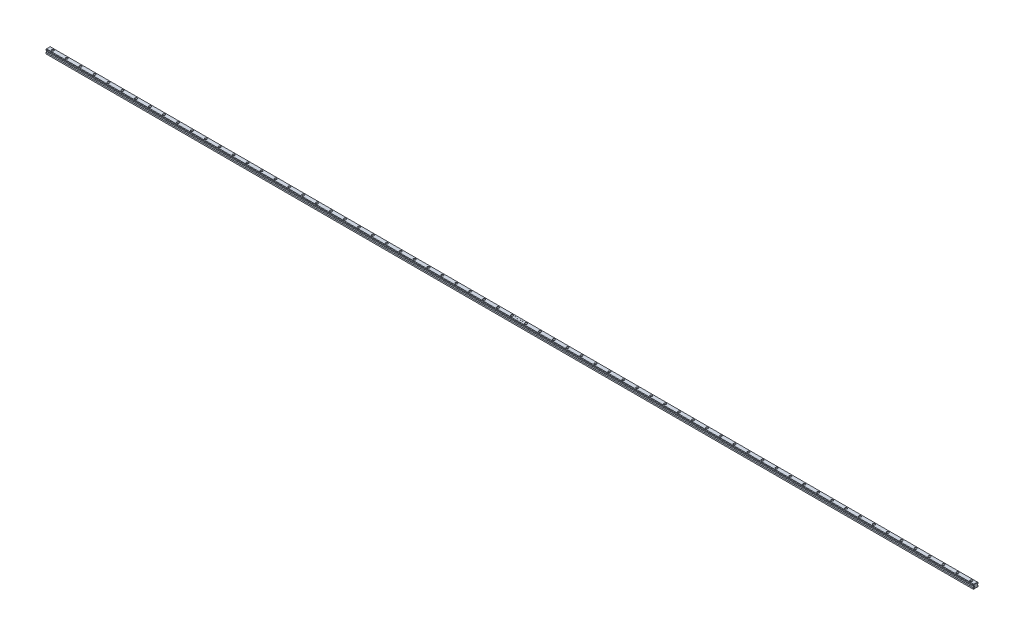
from build123d import *

# Parameters (mm, degrees)
BOSS_EXTRUDE1_DEPTH = 4000
CHAMFER1_SIZE       = 1
CHAMFER2_SIZE       = 1
SKETCH2_R           = 4.75
CUT_EXTRUDE1_DEPTH  = 8.5
SKETCH3_R           = 3
CUT_EXTRUDE2_DEPTH  = 10.5
LPATTERN1_COUNT     = 67
LPATTERN1_PITCH     = 60
CUT_EXTRUDE3_DEPTH  = 2


with BuildPart() as part:
    # Sketch1 → Boss-Extrude1 (new body)
    with BuildSketch(Plane(origin=(0, 0, 0), x_dir=(0, 0, -1), z_dir=(1, 0, 0))):
        Polygon((-10, 0), (10, 0), (10, 6), (7, 8), (7, 10), (10, 13), (10, 16), (8, 18), (-8, 18), (-10, 16), (-10, 13), (-7, 10), (-7, 8), (-10, 6), align=None)
    extrude(amount=BOSS_EXTRUDE1_DEPTH)

    # Chamfer1
    chamfer1_edges = [part.edges().sort_by_distance(p)[0] for p in [
        (0, 7, 8.5),
        (0, 9, 7),
        (0, 11.5, 8.5),
        (0, 14.5, 10),
        (0, 17, 9),
        (0, 18, 0),
        (0, 17, -9),
        (0, 14.5, -10),
        (0, 11.5, -8.5),
        (0, 9, -7),
        (0, 7, -8.5),
        (0, 3, -10),
        (0, 0, 0),
        (0, 3, 10),
    ]]
    chamfer(chamfer1_edges, length=CHAMFER1_SIZE)

    # Chamfer2
    chamfer2_edges = [part.edges().sort_by_distance(p)[0] for p in [
        (4000, 3, -10),
        (4000, 7, -8.5),
        (4000, 9, -7),
        (4000, 11.5, -8.5),
        (4000, 14.5, -10),
        (4000, 17, -9),
        (4000, 18, 0),
        (4000, 17, 9),
        (4000, 14.5, 10),
        (4000, 11.5, 8.5),
        (4000, 3, 10),
        (4000, 9, 7),
        (4000, 7, 8.5),
        (4000, 0, 0),
    ]]
    chamfer(chamfer2_edges, length=CHAMFER2_SIZE)

    # Sketch2 → Cut-Extrude1 (cut)
    with BuildSketch(Plane(origin=(0, 18, 0), x_dir=(1, 0, 0), z_dir=(0, 1, 0))):
        with Locations(Location((3980, 0, 0), (0, 0, 270))):  # turned: the seam where the file's is
            Circle(SKETCH2_R)
    cut_extrude1 = extrude(amount=-CUT_EXTRUDE1_DEPTH, mode=Mode.SUBTRACT)

    # Sketch3 → Cut-Extrude2 (cut, through all)
    with BuildSketch(Plane(origin=(0, 9.5, 0), x_dir=(1, 0, 0), z_dir=(0, 1, 0))):
        with Locations(Location((3980, 0, 0), (0, 0, 270))):  # turned: the seam where the file's is
            Circle(SKETCH3_R)
    cut_extrude2 = extrude(amount=-CUT_EXTRUDE2_DEPTH, mode=Mode.SUBTRACT)

    # LPattern1: Cut-Extrude1, Cut-Extrude2 ×67
    with Locations(*[(-i * LPATTERN1_PITCH, 0, 0) for i in range(1, LPATTERN1_COUNT)]):
        add(cut_extrude1, mode=Mode.SUBTRACT)
        add(cut_extrude2, mode=Mode.SUBTRACT)

    # Sketch4 → Cut-Extrude3 (cut)
    with BuildSketch(Plane(origin=(0, 18, 0), x_dir=(1, 0, 0), z_dir=(0, 1, 0))):
        with BuildLine():
            Line((2010.764930285, -0.382426748), (2011.060803683, -0.205042934))
            add(Edge.make_bspline(
                [(2011.060803683, -0.205042934), (2011.08832192, -0.251107319), (2011.1410458, -0.339364903), (2011.22899716, -0.458622943), (2011.320130071, -0.5599851), (2011.415119404, -0.642861708), (2011.513385352, -0.708110594), (2011.615569406, -0.754312826), (2011.721327217, -0.783128801), (2011.793301038, -0.786628888), (2011.82923317, -0.788376267)],
                knots=[0, 0, 0, 0, 1.272034388, 2.437168799, 3.508375237, 4.49857839, 5.41946034, 6.295179144, 7.148887113, 8, 8, 8, 8], degree=3))
            add(Edge.make_bspline(
                [(2011.82923317, -0.788376267), (2011.85992003, -0.787521595), (2011.920756803, -0.785827205), (2012.010319046, -0.769546402), (2012.097300849, -0.744534274), (2012.179909486, -0.708713342), (2012.257005101, -0.665374856), (2012.324611796, -0.613028679), (2012.383057909, -0.554422473), (2012.430867024, -0.489039818), (2012.467547059, -0.41872267), (2012.495739128, -0.346546719), (2012.511384201, -0.27137815), (2012.513740955, -0.220767687), (2012.514930285, -0.195227229)],
                knots=[0, 0, 0, 0, 1.095163259, 2.171163733, 3.241058638, 4.321873601, 5.38011039, 6.391990106, 7.366004449, 8.327778327, 9.272591725, 10.192022065, 11.087607919, 12, 12, 12, 12], degree=3))
            add(Edge.make_bspline(
                [(2012.514930285, -0.195227229), (2012.513455974, -0.166086379), (2012.510458916, -0.10684729), (2012.485127436, -0.019447637), (2012.445278189, 0.067044933), (2012.408515546, 0.120546199), (2012.389429484, 0.148322451)],
                knots=[0, 0, 0, 0, 0.938893495, 1.908633276, 2.914225137, 4, 4, 4, 4], degree=3))
            add(Edge.make_bspline(
                [(2012.389429484, 0.148322451), (2012.37375887, 0.168369274), (2012.340860375, 0.210455073), (2012.284302863, 0.273100308), (2012.217936748, 0.337718727), (2012.144033194, 0.406777784), (2012.059900105, 0.477065581), (2011.96817259, 0.551933859), (2011.866508731, 0.628535436), (2011.795209235, 0.679908001), (2011.758419868, 0.706415399)],
                knots=[0, 0, 0, 0, 0.722233717, 1.516239348, 2.393582979, 3.351407094, 4.387010283, 5.505090956, 6.712668013, 8, 8, 8, 8], degree=3))
            add(Edge.make_bspline(
                [(2011.758419868, 0.706415399), (2011.721595872, 0.732643987), (2011.651191196, 0.782791049), (2011.552732613, 0.857215333), (2011.46468815, 0.925259203), (2011.387449134, 0.987563215), (2011.321049537, 1.04413582), (2011.264966126, 1.094433759), (2011.220627569, 1.13981732), (2011.195971988, 1.169258661), (2011.18490224, 1.182477098)],
                knots=[0, 0, 0, 0, 1.452282411, 2.77665338, 3.964542531, 5.026858415, 5.96415736, 6.766646006, 7.446254459, 8, 8, 8, 8], degree=3))
            add(Edge.make_bspline(
                [(2011.18490224, 1.182477098), (2011.169429695, 1.203078135), (2011.139000858, 1.243592839), (2011.098834853, 1.306917696), (2011.06469569, 1.371740962), (2011.037933358, 1.438236826), (2011.015397139, 1.505471755), (2011.000239208, 1.574323001), (2010.990747811, 1.64448162), (2010.989775825, 1.69169512), (2010.989289259, 1.715329662)],
                knots=[0, 0, 0, 0, 1.068054152, 2.10047183, 3.106115577, 4.101338837, 5.06977816, 6.043150881, 7.020423561, 8, 8, 8, 8], degree=3))
            add(Edge.make_bspline(
                [(2010.989289259, 1.715329662), (2010.990594468, 1.752359437), (2010.993176989, 1.825627501), (2011.015017506, 1.932658331), (2011.049490399, 2.034844748), (2011.097785287, 2.131175082), (2011.16004264, 2.219141063), (2011.232088615, 2.29975455), (2011.317900101, 2.367523132), (2011.412052724, 2.42673519), (2011.515109096, 2.473081116), (2011.6231, 2.508042096), (2011.736197072, 2.527851353), (2011.812800206, 2.530694118), (2011.851669067, 2.532136553)],
                knots=[0, 0, 0, 0, 1.005424448, 1.989358655, 2.955360095, 3.929531133, 4.905563448, 5.876582895, 6.856512386, 7.866279853, 8.892233794, 9.918561126, 10.94386622, 12, 12, 12, 12], degree=3))
            add(Edge.make_bspline(
                [(2011.851669067, 2.532136553), (2011.892913167, 2.530714002), (2011.974934519, 2.527885001), (2012.095583735, 2.503287469), (2012.211744451, 2.462586797), (2012.305187716, 2.416398139), (2012.378320477, 2.370266724), (2012.43409321, 2.328246899), (2012.490610661, 2.279871791), (2012.548328716, 2.225012545), (2012.606269375, 2.163165794), (2012.665292827, 2.094755105), (2012.725537096, 2.020198549), (2012.764292956, 1.966974048), (2012.784161054, 1.939688637)],
                knots=[0, 0, 0, 0, 1.286793592, 2.559021753, 3.825965368, 5.121522368, 5.803751409, 6.523245864, 7.299691795, 8.125521123, 9.008227632, 9.944561021, 10.946284179, 12, 12, 12, 12], degree=3))
            Line((2012.784161054, 1.939688637), (2012.500206727, 1.724444246))
            add(Edge.make_bspline(
                [(2012.500206727, 1.724444246), (2012.483060795, 1.746532936), (2012.450041738, 1.789070589), (2012.399912251, 1.848641905), (2012.352663603, 1.903058384), (2012.306113203, 1.950323512), (2012.262719572, 1.993025646), (2012.22060253, 2.029585403), (2012.180368178, 2.060360998), (2012.129651268, 2.093204558), (2012.065933549, 2.125761061), (2011.985949013, 2.15331014), (2011.902362738, 2.169865201), (2011.845433107, 2.172054089), (2011.816612977, 2.173162194)],
                knots=[0, 0, 0, 0, 1.181633172, 2.275549214, 3.290209073, 4.226197932, 5.078386478, 5.862611352, 6.581680152, 7.217281963, 8.414376989, 9.595101626, 10.782541182, 12, 12, 12, 12], degree=3))
            add(Edge.make_bspline(
                [(2011.816612977, 2.173162194), (2011.780456455, 2.171950494), (2011.710732008, 2.169613845), (2011.611741772, 2.14409386), (2011.522647846, 2.103911999), (2011.446095281, 2.047597021), (2011.382358304, 1.980876029), (2011.336252846, 1.904097174), (2011.308502681, 1.819314771), (2011.305116401, 1.760173115), (2011.303391824, 1.73005322)],
                knots=[0, 0, 0, 0, 1.14458467, 2.207223713, 3.21896685, 4.227309161, 5.202851033, 6.127160689, 7.046193047, 8, 8, 8, 8], degree=3))
            add(Edge.make_bspline(
                [(2011.303391824, 1.73005322), (2011.30378495, 1.711301741), (2011.304571846, 1.673768122), (2011.315546644, 1.6183167), (2011.329645973, 1.563005361), (2011.351988605, 1.508082778), (2011.382833908, 1.452588419), (2011.423339084, 1.395566681), (2011.474352396, 1.336514972), (2011.513429409, 1.298107599), (2011.534060894, 1.277829662)],
                knots=[0, 0, 0, 0, 0.858281714, 1.717966888, 2.583508476, 3.4729293, 4.427298488, 5.488583878, 6.674047936, 8, 8, 8, 8], degree=3))
            add(Edge.make_bspline(
                [(2011.534060894, 1.277829662), (2011.541722267, 1.270992636), (2011.559923934, 1.254749428), (2011.593199859, 1.228157147), (2011.637142658, 1.195354375), (2011.690604859, 1.154767059), (2011.754572221, 1.107685597), (2011.829051777, 1.054711984), (2011.913213309, 0.994126525), (2011.972935225, 0.951768985), (2012.004513618, 0.92937213)],
                knots=[0, 0, 0, 0, 0.420754252, 0.999615792, 1.744751191, 2.668019286, 3.750313428, 4.999500688, 6.413464383, 8, 8, 8, 8], degree=3))
            add(Edge.make_bspline(
                [(2012.004513618, 0.92937213), (2012.042499532, 0.901730771), (2012.116053988, 0.848207109), (2012.220711568, 0.767791429), (2012.315605376, 0.68914366), (2012.40106858, 0.612766053), (2012.477945488, 0.53923796), (2012.545383209, 0.46767478), (2012.604068889, 0.398589207), (2012.667248108, 0.310016631), (2012.731805927, 0.201235547), (2012.787247435, 0.067957309), (2012.822205782, -0.065839012), (2012.826777297, -0.155765848), (2012.829032849, -0.200135081)],
                knots=[0, 0, 0, 0, 1.163667725, 2.253281268, 3.268753668, 4.215851969, 5.092017293, 5.902905408, 6.650798638, 7.335211899, 8.59617414, 9.77448103, 10.901945474, 12, 12, 12, 12], degree=3))
            add(Edge.make_bspline(
                [(2012.829032849, -0.200135081), (2012.828375711, -0.231513446), (2012.827074196, -0.29366083), (2012.812113282, -0.384915907), (2012.790193617, -0.473546777), (2012.757156383, -0.558457889), (2012.716833225, -0.641202652), (2012.665666977, -0.719610552), (2012.606359292, -0.795416951), (2012.538325527, -0.866600442), (2012.463879625, -0.931946638), (2012.38519593, -0.9900757), (2012.302145657, -1.038544023), (2012.215179341, -1.078094865), (2012.124277004, -1.109028382), (2012.02946922, -1.131441252), (2011.930599709, -1.145196963), (2011.863399227, -1.146624724), (2011.82923317, -1.147350626)],
                knots=[0, 0, 0, 0, 0.983748083, 1.948392443, 2.894712957, 3.844097841, 4.80183111, 5.778335162, 6.776009319, 7.81870978, 8.863265674, 9.881300176, 10.883814829, 11.87499822, 12.874611388, 13.892143829, 14.928324115, 16, 16, 16, 16], degree=3))
            add(Edge.make_bspline(
                [(2011.82923317, -1.147350626), (2011.802797827, -1.146839445), (2011.750260067, -1.145823519), (2011.672550585, -1.136842239), (2011.596410996, -1.124135135), (2011.522796714, -1.103961065), (2011.450759302, -1.079484088), (2011.380612067, -1.049345756), (2011.312321014, -1.013228554), (2011.245503431, -0.97193353), (2011.180329256, -0.923875785), (2011.117409788, -0.867902289), (2011.054680603, -0.805556784), (2010.993993206, -0.73514622), (2010.934120062, -0.657808137), (2010.876241653, -0.572818954), (2010.819159935, -0.4806416), (2010.783344467, -0.415776514), (2010.764930285, -0.382426748)],
                knots=[0, 0, 0, 0, 0.915332311, 1.819136955, 2.706846663, 3.586547465, 4.459518054, 5.340707479, 6.227863349, 7.133153174, 8.059268498, 9.028702269, 10.047606654, 11.120612155, 12.245963614, 13.433783089, 14.680604001, 16, 16, 16, 16], degree=3))
        make_face()
        Polygon((2015.62005849, 2.442392963), (2015.934161054, 2.442392963), (2015.934161054, 1.006495528), (2017.729032849, 1.006495528), (2017.729032849, 2.442392963), (2018.043135413, 2.442392963), (2018.043135413, -1.057607037), (2017.729032849, -1.057607037), (2017.729032849, 0.647521169), (2015.934161054, 0.647521169), (2015.934161054, -1.057607037), (2015.62005849, -1.057607037), align=None)
        Polygon((2021.013648234, -1.057607037), (2021.013648234, 2.442392963), (2021.079553683, 2.442392963), (2023.391853362, -0.312314569), (2023.391853362, 2.442392963), (2023.705955926, 2.442392963), (2023.705955926, -1.057607037), (2023.634441503, -1.057607037), (2021.327750798, 1.690790399), (2021.327750798, -1.057607037), align=None)
        with BuildLine():
            Line((2030.230314901, 1.365469887), (2029.916212336, 1.365469887))
            add(Edge.make_bspline(
                [(2029.916212336, 1.365469887), (2029.918259489, 1.407140774), (2029.922280043, 1.488981289), (2029.941108333, 1.608305195), (2029.96804921, 1.722359994), (2030.006140664, 1.830229908), (2030.053446942, 1.932868715), (2030.110176969, 2.029868731), (2030.17737082, 2.12085992), (2030.253577554, 2.204998763), (2030.336346193, 2.282186334), (2030.425652132, 2.348841577), (2030.519497159, 2.405159248), (2030.617596558, 2.45224049), (2030.721057122, 2.487580336), (2030.82893998, 2.513801975), (2030.941719116, 2.529578321), (2031.018559138, 2.531274107), (2031.057638618, 2.532136553)],
                knots=[0, 0, 0, 0, 1.10065271, 2.161652631, 3.183658789, 4.190468796, 5.17591951, 6.163126047, 7.15150782, 8.156236427, 9.156009102, 10.134482811, 11.092018607, 12.041330605, 13.001268258, 13.972401359, 14.968799086, 16, 16, 16, 16], degree=3))
            add(Edge.make_bspline(
                [(2031.057638618, 2.532136553), (2031.096016693, 2.531238097), (2031.171428237, 2.529472662), (2031.281490252, 2.514311633), (2031.386267546, 2.490566041), (2031.485555313, 2.457250625), (2031.578561377, 2.412466197), (2031.665984422, 2.358668659), (2031.748865233, 2.296448827), (2031.823472016, 2.223195014), (2031.891980095, 2.144992629), (2031.951082351, 2.061504726), (2032.001695514, 1.97527544), (2032.043883194, 1.885647238), (2032.074939333, 1.79177621), (2032.098517541, 1.695029007), (2032.111844955, 1.594404196), (2032.113890378, 1.526297641), (2032.114930285, 1.49167181)],
                knots=[0, 0, 0, 0, 1.111607364, 2.184268762, 3.212621178, 4.221274766, 5.211760367, 6.196651075, 7.1921475, 8.207485113, 9.220403448, 10.201281604, 11.166441695, 12.114753415, 13.065576456, 14.026450734, 14.996634279, 16, 16, 16, 16], degree=3))
            add(Edge.make_bspline(
                [(2032.114930285, 1.49167181), (2032.113237022, 1.442923975), (2032.109880211, 1.346283761), (2032.081165834, 1.204268899), (2032.036319323, 1.06667548), (2031.982321966, 0.955938177), (2031.927849522, 0.866704684), (2031.878762015, 0.793235979), (2031.821297204, 0.71413051), (2031.754618706, 0.629653173), (2031.680105834, 0.539142268), (2031.59708367, 0.442652473), (2031.504960188, 0.341180703), (2031.440301687, 0.271875101), (2031.406797272, 0.235962675)],
                knots=[0, 0, 0, 0, 1.184426356, 2.348067706, 3.509069118, 4.696110526, 5.333549288, 6.050745305, 6.844228056, 7.710549037, 8.667450064, 9.695053472, 10.805634456, 12, 12, 12, 12], degree=3))
            Line((2031.406797272, 0.235962675), (2030.531096151, -0.698632678))
            Line((2030.531096151, -0.698632678), (2032.15980208, -0.698632678))
            Line((2032.15980208, -0.698632678), (2032.15980208, -1.057607037))
            Line((2032.15980208, -1.057607037), (2029.781596952, -1.057607037))
            Line((2029.781596952, -1.057607037), (2031.138968747, 0.390910592))
            add(Edge.make_bspline(
                [(2031.138968747, 0.390910592), (2031.172016633, 0.425408898), (2031.235494861, 0.491673085), (2031.325277437, 0.588416045), (2031.405916426, 0.678165586), (2031.477933818, 0.760752134), (2031.539767324, 0.837383702), (2031.594639556, 0.905578406), (2031.638605147, 0.968332856), (2031.686320542, 1.04107347), (2031.732534524, 1.129885787), (2031.77224688, 1.238419476), (2031.796461728, 1.350146729), (2031.799366564, 1.425648766), (2031.800827721, 1.463626938)],
                knots=[0, 0, 0, 0, 1.329631726, 2.553950428, 3.673215718, 4.687767853, 5.603093632, 6.413772471, 7.123043292, 7.734684054, 8.834405432, 9.900288307, 10.943827018, 12, 12, 12, 12], degree=3))
            add(Edge.make_bspline(
                [(2031.800827721, 1.463626938), (2031.800191979, 1.487508336), (2031.798939053, 1.534573987), (2031.787881355, 1.603579746), (2031.771170849, 1.670144559), (2031.747225591, 1.734473179), (2031.715618851, 1.795918831), (2031.677145471, 1.854556311), (2031.632755408, 1.911245276), (2031.581404138, 1.964398574), (2031.524992619, 2.01307978), (2031.465398369, 2.056203865), (2031.402348265, 2.092242976), (2031.336108143, 2.121786473), (2031.266862673, 2.144961854), (2031.194477928, 2.161020434), (2031.119153912, 2.171102918), (2031.067720416, 2.172467089), (2031.041512817, 2.173162194)],
                knots=[0, 0, 0, 0, 0.991446411, 1.95395049, 2.89581595, 3.838931463, 4.798493298, 5.75982156, 6.748411868, 7.785213223, 8.824556874, 9.840280684, 10.836137867, 11.835679398, 12.848801643, 13.863922112, 14.911575587, 16, 16, 16, 16], degree=3))
            add(Edge.make_bspline(
                [(2031.041512817, 2.173162194), (2031.014141984, 2.172447162), (2030.960390188, 2.171042957), (2030.881471155, 2.161220293), (2030.806185378, 2.144274452), (2030.734343475, 2.121097778), (2030.665823889, 2.091639229), (2030.600959845, 2.054947484), (2030.539896956, 2.011163991), (2030.482520432, 1.961523435), (2030.429656453, 1.906255834), (2030.383209577, 1.844645871), (2030.342625563, 1.777818455), (2030.30721633, 1.705953905), (2030.27846064, 1.628400125), (2030.256487489, 1.54543242), (2030.239100643, 1.457411038), (2030.233292122, 1.396625954), (2030.230314901, 1.365469887)],
                knots=[0, 0, 0, 0, 1.031018746, 2.02475058, 2.990194455, 3.934040569, 4.864654155, 5.795059489, 6.735614925, 7.690564532, 8.649604399, 9.611025574, 10.590972636, 11.591080095, 12.624614302, 13.701020113, 14.821632451, 16, 16, 16, 16], degree=3))
        make_face()
        with BuildLine():
            add(Edge.make_bspline(
                [(2034.546981567, 0.69099072), (2034.547309585, 0.747088108), (2034.547946765, 0.856058092), (2034.555035186, 1.014842734), (2034.566810529, 1.163803023), (2034.582947901, 1.302946089), (2034.602585882, 1.432307853), (2034.628801368, 1.551542611), (2034.658614171, 1.661202217), (2034.693166617, 1.761644266), (2034.732154406, 1.854221969), (2034.774588666, 1.94064717), (2034.822153461, 2.020789102), (2034.872130374, 2.095926893), (2034.926542445, 2.164830588), (2034.983841236, 2.22847325), (2035.046263112, 2.285384001), (2035.11168612, 2.337230303), (2035.180702585, 2.382679775), (2035.251345251, 2.422712513), (2035.324100357, 2.456912381), (2035.39916654, 2.483802816), (2035.475869098, 2.506013663), (2035.554476164, 2.521202611), (2035.635117528, 2.530759519), (2035.689548963, 2.531673187), (2035.717153843, 2.532136553)],
                knots=[0, 0, 0, 0, 1.646270934, 3.197905019, 4.663502075, 6.030701355, 7.308322542, 8.50163776, 9.611534131, 10.641858119, 11.616356847, 12.558055219, 13.465016945, 14.349605745, 15.204443733, 16.039544428, 16.859896111, 17.680448484, 18.487036065, 19.28249412, 20.06191084, 20.843045899, 21.620316918, 22.403196591, 23.190181807, 24, 24, 24, 24], degree=3))
            add(Edge.make_bspline(
                [(2035.717153843, 2.532136553), (2035.744989321, 2.531648738), (2035.80034533, 2.530678627), (2035.882185705, 2.521354685), (2035.962135387, 2.505883562), (2036.039853526, 2.483962587), (2036.115978512, 2.45676691), (2036.18991492, 2.422679793), (2036.262122002, 2.383000926), (2036.331452289, 2.336377049), (2036.398666904, 2.284394772), (2036.462114867, 2.225632104), (2036.521801953, 2.160682384), (2036.578477259, 2.09024052), (2036.630532856, 2.012955436), (2036.680106288, 1.930171326), (2036.724478324, 1.840440461), (2036.767212999, 1.745259993), (2036.804099986, 1.641996334), (2036.837366231, 1.531231574), (2036.8642452, 1.411657387), (2036.886634472, 1.283901142), (2036.903979368, 1.147493658), (2036.91661201, 1.002727343), (2036.923285095, 0.849506952), (2036.924541796, 0.744749103), (2036.925186695, 0.69099072)],
                knots=[0, 0, 0, 0, 0.810914788, 1.612654377, 2.396697861, 3.181598691, 3.963628158, 4.749916497, 5.551656086, 6.361998678, 7.18212741, 8.025565596, 8.878627764, 9.750805457, 10.657531673, 11.591944965, 12.560506719, 13.57287815, 14.630710178, 15.753379473, 16.941251878, 18.199788006, 19.531962791, 20.947069417, 22.433333509, 24, 24, 24, 24], degree=3))
            add(Edge.make_bspline(
                [(2036.925186695, 0.69099072), (2036.924535111, 0.637466812), (2036.923265525, 0.53317766), (2036.916686818, 0.380646685), (2036.903728187, 0.236648641), (2036.887518199, 0.100838179), (2036.865067236, -0.02621944), (2036.837462069, -0.144963888), (2036.806811747, -0.25590796), (2036.768976953, -0.358142772), (2036.727566242, -0.453094494), (2036.682511046, -0.541761643), (2036.63424122, -0.624927935), (2036.581652475, -0.701927682), (2036.525599062, -0.773306339), (2036.464881273, -0.837803962), (2036.401210688, -0.896974634), (2036.333798272, -0.949626262), (2036.263386721, -0.995711066), (2036.191427644, -1.036924917), (2036.11664426, -1.070157612), (2036.040731308, -1.098692653), (2035.962602942, -1.120493104), (2035.882356551, -1.13556696), (2035.800400315, -1.146138808), (2035.74499875, -1.146945288), (2035.717153843, -1.147350626)],
                knots=[0, 0, 0, 0, 1.561518951, 3.042555995, 4.452378317, 5.7783523, 7.031515105, 8.214008947, 9.334062868, 10.386615937, 11.391082383, 12.354592575, 13.286541444, 14.194233754, 15.072674879, 15.931287219, 16.775624067, 17.606195743, 18.42308326, 19.229000347, 20.022332153, 20.807536673, 21.593273796, 22.3848459, 23.188221202, 24, 24, 24, 24], degree=3))
            add(Edge.make_bspline(
                [(2035.717153843, -1.147350626), (2035.689549729, -1.146884271), (2035.635119804, -1.145964709), (2035.554467379, -1.136450977), (2035.476184935, -1.121155474), (2035.399886181, -1.09973887), (2035.325179666, -1.073524034), (2035.253083379, -1.03937035), (2035.182795696, -1.000036281), (2035.11450414, -0.95524086), (2035.049491979, -0.903919177), (2034.987393373, -0.847154888), (2034.929768354, -0.783531477), (2034.876134259, -0.714053554), (2034.82516017, -0.639360311), (2034.778270797, -0.558431938), (2034.734899943, -0.471589328), (2034.695256452, -0.378271417), (2034.660107789, -0.277116489), (2034.629060081, -0.166967311), (2034.604545923, -0.046851675), (2034.583562968, 0.082265693), (2034.566638585, 0.220939623), (2034.55508426, 0.369245401), (2034.547942945, 0.52709061), (2034.547307874, 0.635360384), (2034.546981567, 0.69099072)],
                knots=[0, 0, 0, 0, 0.810891512, 1.598919785, 2.382837074, 3.152667961, 3.926044502, 4.706494248, 5.493654104, 6.291793342, 7.103789334, 7.925228297, 8.761435821, 9.622817696, 10.50288917, 11.416980706, 12.369136599, 13.353924996, 14.394355917, 15.514179734, 16.714354668, 17.994756427, 19.357759367, 20.818452758, 22.365282078, 24, 24, 24, 24], degree=3))
        make_face()
        with BuildLine():
            add(Edge.make_bspline(
                [(2034.861084131, 0.692392963), (2034.861203578, 0.645644265), (2034.861435402, 0.55491422), (2034.867491602, 0.423070959), (2034.875741834, 0.30010063), (2034.886383131, 0.185847094), (2034.90218608, 0.080697081), (2034.919892868, -0.016072602), (2034.941440957, -0.103949839), (2034.966935975, -0.18353765), (2034.995975072, -0.256186718), (2035.027680936, -0.323787933), (2035.061741659, -0.38713987), (2035.099860809, -0.445673478), (2035.141375872, -0.499579642), (2035.185349132, -0.549812475), (2035.233421716, -0.594609456), (2035.299925458, -0.648336311), (2035.387721933, -0.703855445), (2035.498342388, -0.752201535), (2035.612010839, -0.782583991), (2035.689162089, -0.786447747), (2035.72767067, -0.788376267)],
                knots=[0, 0, 0, 0, 1.459021318, 2.831673884, 4.118529203, 5.306027144, 6.411944654, 7.436330062, 8.375795394, 9.233974572, 10.042671642, 10.816086306, 11.563610507, 12.285937304, 12.993564865, 13.685989202, 14.367179055, 15.041617293, 16.353048772, 17.594441528, 18.799311195, 20, 20, 20, 20], degree=3))
            add(Edge.make_bspline(
                [(2035.72767067, -0.788376267), (2035.766428341, -0.786778486), (2035.843863665, -0.783586224), (2035.95699746, -0.752787486), (2036.06682773, -0.706317947), (2036.15289967, -0.651370441), (2036.218382214, -0.599042112), (2036.265299204, -0.554427464), (2036.308361252, -0.504471596), (2036.349203327, -0.4505723), (2036.386662403, -0.391699816), (2036.42072554, -0.328137241), (2036.451808888, -0.259708063), (2036.469517934, -0.211938324), (2036.478572112, -0.187514889)],
                knots=[0, 0, 0, 0, 1.353760809, 2.704726607, 4.075137775, 5.516104923, 6.260822281, 7.007110065, 7.778089737, 8.566572457, 9.372053459, 10.217411131, 11.088608312, 12, 12, 12, 12], degree=3))
            add(Edge.make_bspline(
                [(2036.478572112, -0.187514889), (2036.48912388, -0.15628515), (2036.510548494, -0.092875385), (2036.538160268, 0.005488267), (2036.559905667, 0.108691031), (2036.579469033, 0.216116147), (2036.592822089, 0.328555848), (2036.603569902, 0.445662232), (2036.609900589, 0.567523595), (2036.61068534, 0.650318586), (2036.611084131, 0.692392963)],
                knots=[0, 0, 0, 0, 0.884706709, 1.796334032, 2.740027952, 3.714592787, 4.726048262, 5.777819803, 6.87074269, 8, 8, 8, 8], degree=3))
            add(Edge.make_bspline(
                [(2036.611084131, 0.692392963), (2036.610533942, 0.734460536), (2036.609457654, 0.816753701), (2036.605343667, 0.937271881), (2036.594720092, 1.051739642), (2036.582920973, 1.160650115), (2036.565523752, 1.263400418), (2036.546765945, 1.360850723), (2036.521564733, 1.451793748), (2036.494644958, 1.53765333), (2036.463834562, 1.617453984), (2036.429918828, 1.69156777), (2036.393697069, 1.760352495), (2036.354354829, 1.823619437), (2036.312359146, 1.88165198), (2036.266601597, 1.933286574), (2036.218897224, 1.980123542), (2036.152080038, 2.033586111), (2036.064605748, 2.088097807), (2035.955760101, 2.138263567), (2035.842489457, 2.167071859), (2035.765916003, 2.171133546), (2035.72767067, 2.173162194)],
                knots=[0, 0, 0, 0, 1.31362396, 2.569729283, 3.763502607, 4.902122613, 5.988968491, 7.01645872, 7.998833611, 8.933434873, 9.825090667, 10.667526885, 11.477055099, 12.250526234, 12.991942729, 13.710640831, 14.402115721, 15.076753259, 16.378508321, 17.609869233, 18.806226677, 20, 20, 20, 20], degree=3))
            add(Edge.make_bspline(
                [(2035.72767067, 2.173162194), (2035.688960078, 2.171130748), (2035.611468372, 2.167064154), (2035.497020417, 2.1383709), (2035.387316066, 2.088357934), (2035.300073091, 2.033405562), (2035.233209304, 1.98106725), (2035.186126611, 1.935680796), (2035.141980439, 1.886034542), (2035.101312739, 1.831632627), (2035.063223456, 1.773167259), (2035.028242443, 1.710178495), (2034.996725113, 1.642347131), (2034.967640577, 1.569730695), (2034.942067789, 1.490149751), (2034.920973826, 1.402380757), (2034.901486773, 1.305918865), (2034.887691504, 1.200199357), (2034.875427748, 1.085917204), (2034.8675464, 0.962639886), (2034.861415143, 0.830575505), (2034.861196678, 0.739376347), (2034.861084131, 0.692392963)],
                knots=[0, 0, 0, 0, 1.207732386, 2.417664972, 3.655092373, 4.956220595, 5.625982001, 6.301752483, 6.994047911, 7.697131622, 8.419323945, 9.170223765, 9.943494443, 10.752040957, 11.610060368, 12.549350801, 13.567764191, 14.679664412, 15.874934091, 17.154273443, 18.533957287, 20, 20, 20, 20], degree=3))
        make_face(mode=Mode.SUBTRACT)
        with BuildLine():
            Line((2043.045699516, 2.442392963), (2043.728592144, 2.442392963))
            add(Edge.make_bspline(
                [(2043.728592144, 2.442392963), (2043.762020622, 2.442217213), (2043.826813333, 2.441876565), (2043.921032774, 2.436593434), (2044.009281585, 2.429389764), (2044.091585357, 2.417959671), (2044.16790606, 2.404167894), (2044.238473697, 2.387466078), (2044.303063869, 2.367439465), (2044.380176606, 2.335593183), (2044.468097267, 2.288270015), (2044.563295659, 2.21834145), (2044.644699899, 2.132808987), (2044.714886216, 2.036326331), (2044.770687336, 1.930190559), (2044.811056633, 1.816931371), (2044.836614508, 1.698009629), (2044.839242942, 1.616366451), (2044.840571311, 1.575105303)],
                knots=[0, 0, 0, 0, 1.001505555, 1.941167018, 2.826882275, 3.653841531, 4.429895133, 5.150066043, 5.825578002, 6.45369114, 7.647487171, 8.808567382, 9.977351308, 11.170798116, 12.373658725, 13.556498008, 14.765093433, 16, 16, 16, 16], degree=3))
            add(Edge.make_bspline(
                [(2044.840571311, 1.575105303), (2044.839478092, 1.536452748), (2044.837329815, 1.460496831), (2044.816787056, 1.349402721), (2044.784626387, 1.243651502), (2044.739921138, 1.143629117), (2044.681819142, 1.051595504), (2044.612960823, 0.966808238), (2044.529884021, 0.892857181), (2044.467640781, 0.851514278), (2044.436024035, 0.830513957)],
                knots=[0, 0, 0, 0, 1.044552857, 2.05264487, 3.044412934, 4.028983338, 5.005914585, 5.980388656, 6.974128949, 8, 8, 8, 8], degree=3))
            add(Edge.make_bspline(
                [(2044.436024035, 0.830513957), (2044.475784463, 0.815248958), (2044.55185601, 0.786043234), (2044.656542023, 0.73440777), (2044.746736868, 0.678245659), (2044.823134014, 0.616913809), (2044.888471668, 0.550804998), (2044.94552461, 0.478949884), (2044.994205984, 0.400411126), (2045.035918908, 0.316007591), (2045.068467664, 0.226601123), (2045.092843568, 0.133030346), (2045.106811017, 0.035630791), (2045.108798659, -0.030654588), (2045.10980208, -0.064117453)],
                knots=[0, 0, 0, 0, 1.27268992, 2.434971085, 3.483601985, 4.442670787, 5.356604649, 6.2567628, 7.179492994, 8.113709626, 9.066344395, 10.018646069, 10.999752585, 12, 12, 12, 12], degree=3))
            add(Edge.make_bspline(
                [(2045.10980208, -0.064117453), (2045.108825234, -0.098284325), (2045.106903262, -0.165508603), (2045.09272329, -0.264263738), (2045.068714183, -0.358638685), (2045.035643037, -0.449243867), (2044.992480722, -0.535904002), (2044.939952758, -0.618717266), (2044.877321194, -0.696851596), (2044.807258325, -0.771175219), (2044.72799618, -0.838003007), (2044.642480425, -0.897518713), (2044.549634105, -0.946464776), (2044.450982111, -0.987580797), (2044.345417795, -1.018987996), (2044.233415188, -1.040960569), (2044.115070886, -1.055765606), (2044.033861135, -1.056982811), (2043.992213939, -1.057607037)],
                knots=[0, 0, 0, 0, 0.978564426, 1.925352924, 2.850884081, 3.763762016, 4.682927383, 5.618979971, 6.567305752, 7.547517671, 8.540179244, 9.531824382, 10.526200242, 11.540722885, 12.589160233, 13.674978461, 14.80764778, 16, 16, 16, 16], degree=3))
            Line((2043.992213939, -1.057607037), (2043.045699516, -1.057607037))
            Line((2043.045699516, -1.057607037), (2043.045699516, 2.442392963))
        make_face()
        with BuildLine():
            Line((2043.35980208, 2.083418605), (2043.35980208, 0.961623733))
            Line((2043.35980208, 0.961623733), (2043.57083974, 0.961623733))
            add(Edge.make_bspline(
                [(2043.57083974, 0.961623733), (2043.601688536, 0.962023656), (2043.661294695, 0.962796388), (2043.747614591, 0.965009906), (2043.82773961, 0.971207949), (2043.901531443, 0.977404211), (2043.968873887, 0.987478799), (2044.029617748, 0.999470922), (2044.084716345, 1.012153827), (2044.148255891, 1.033723314), (2044.220328839, 1.065600989), (2044.297161943, 1.115072825), (2044.364896413, 1.173997178), (2044.422093601, 1.24198814), (2044.468905071, 1.316854326), (2044.501418786, 1.397401206), (2044.52346607, 1.481621338), (2044.525457602, 1.539439591), (2044.526468747, 1.568795207)],
                knots=[0, 0, 0, 0, 1.156816544, 2.235205308, 3.236616184, 4.169592532, 5.011045266, 5.787822928, 6.49130361, 7.128639758, 8.301311294, 9.436451833, 10.541879658, 11.654887649, 12.756523258, 13.837046038, 14.901820046, 16, 16, 16, 16], degree=3))
            add(Edge.make_bspline(
                [(2044.526468747, 1.568795207), (2044.525942566, 1.588220979), (2044.524910407, 1.626326751), (2044.516457104, 1.681876105), (2044.50208953, 1.734119857), (2044.483635236, 1.783773968), (2044.457846548, 1.829285818), (2044.427483084, 1.872229014), (2044.390797394, 1.911141132), (2044.349040081, 1.94751063), (2044.301031458, 1.979755158), (2044.246800167, 2.007995921), (2044.18561249, 2.030736698), (2044.118499635, 2.050652851), (2044.044428547, 2.064641144), (2043.964253994, 2.076294532), (2043.877319275, 2.082227274), (2043.817174172, 2.083012637), (2043.786084131, 2.083418605)],
                knots=[0, 0, 0, 0, 0.91205012, 1.789085906, 2.630437955, 3.453916878, 4.269457761, 5.079663411, 5.91843418, 6.774407191, 7.675494373, 8.627863946, 9.638891023, 10.736472738, 11.911756761, 13.175263542, 14.539845004, 16, 16, 16, 16], degree=3))
            Line((2043.786084131, 2.083418605), (2043.35980208, 2.083418605))
        make_face(mode=Mode.SUBTRACT)
        with BuildLine():
            Line((2043.35980208, 0.602649374), (2043.35980208, -0.698632678))
            Line((2043.35980208, -0.698632678), (2043.807117785, -0.698632678))
            add(Edge.make_bspline(
                [(2043.807117785, -0.698632678), (2043.839136711, -0.69824893), (2043.90084897, -0.697509308), (2043.9899502, -0.695094753), (2044.072533304, -0.689602477), (2044.148221439, -0.680956628), (2044.217831892, -0.671578179), (2044.280529595, -0.658966898), (2044.336822788, -0.644517937), (2044.402097096, -0.622183765), (2044.475600604, -0.587487294), (2044.554811461, -0.535173068), (2044.625237679, -0.47284976), (2044.685042938, -0.400718846), (2044.734055927, -0.322287519), (2044.769711382, -0.239142169), (2044.791702238, -0.152656641), (2044.794364408, -0.093689929), (2044.795699516, -0.064117453)],
                knots=[0, 0, 0, 0, 1.160039823, 2.235823828, 3.228722157, 4.157150951, 4.99529583, 5.772374946, 6.472645482, 7.099169577, 8.269452708, 9.405989375, 10.527446681, 11.663510218, 12.788923519, 13.866172445, 14.929861265, 16, 16, 16, 16], degree=3))
            add(Edge.make_bspline(
                [(2044.795699516, -0.064117453), (2044.795423412, -0.045624113), (2044.794875656, -0.008935731), (2044.786615042, 0.044980088), (2044.774601172, 0.097205962), (2044.759069738, 0.147883702), (2044.736450271, 0.196097078), (2044.710043726, 0.242799638), (2044.679082324, 0.288053117), (2044.630838158, 0.345265371), (2044.560666174, 0.411182384), (2044.460959398, 0.475719886), (2044.3475871, 0.527767693), (2044.265359607, 0.549867169), (2044.222883009, 0.561283188)],
                knots=[0, 0, 0, 0, 0.723448775, 1.435228256, 2.130040452, 2.821711965, 3.505591119, 4.210454504, 4.921174351, 5.648778258, 7.137944449, 8.670945889, 10.280296675, 12, 12, 12, 12], degree=3))
            add(Edge.make_bspline(
                [(2044.222883009, 0.561283188), (2044.205853914, 0.564738272), (2044.168931321, 0.572229606), (2044.108723741, 0.58013731), (2044.039987872, 0.58718237), (2043.962564995, 0.592393527), (2043.876357154, 0.597780071), (2043.781180235, 0.599874892), (2043.67742292, 0.602374152), (2043.605430548, 0.602555286), (2043.568035253, 0.602649374)],
                knots=[0, 0, 0, 0, 0.634451884, 1.375622551, 2.216452059, 3.157844607, 4.20941857, 5.370758133, 6.634282058, 8, 8, 8, 8], degree=3))
            Line((2043.568035253, 0.602649374), (2043.35980208, 0.602649374))
        make_face(mode=Mode.SUBTRACT)
    extrude(amount=-CUT_EXTRUDE3_DEPTH, mode=Mode.SUBTRACT)


solid = part.part
